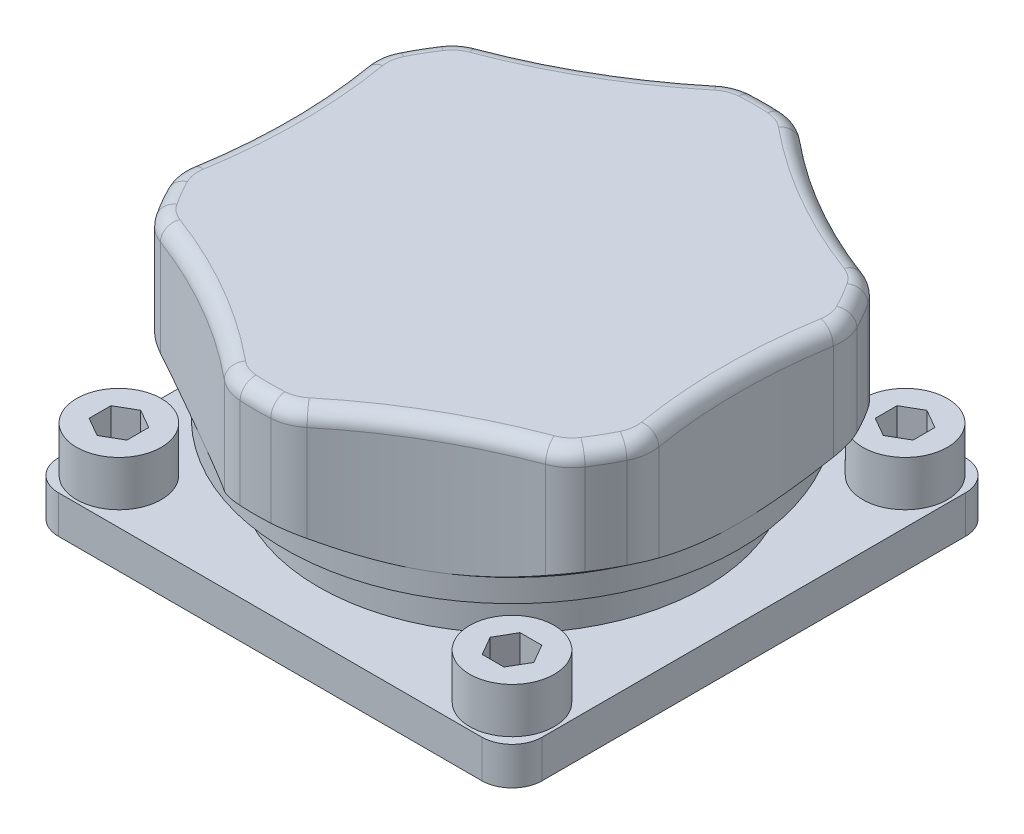
from build123d import *

# Parameters (mm, degrees)
EXTRUDE_1_DEPTH          = 2.5
SKETCH_2_R               = 12.8
EXTRUDE_2_DEPTH          = 10
EXTRUDE_START            = 3.25
SKETCH_3_R               = 17
EXTRUDE_3_DEPTH          = 10
SKETCH_5_R               = 35
CUT_EXTRUDE_2_DEPTH      = 10
SKETCH_7_R               = 2.8
EXTRUDE_4_DEPTH          = 3
CUT_EXTRUDE_4_DEPTH      = 2
PATTERN_CIRCULAR_1_COUNT = 4
FILLET_1_R               = 3
FILLET_2_R               = 1


with BuildPart() as part:
    # 草图1 → 凸台-拉伸1 (new body)
    with BuildSketch(Plane(origin=(0, 0, 0), x_dir=(1, 0, 0), z_dir=(0, 1, 0))):
        with BuildLine():
            Line((14, -16), (-14, -16))
            ThreePointArc((-14, -16), (-15.414213562, -15.414213562), (-16, -14))
            Line((-16, -14), (-16, 14))
            ThreePointArc((-16, 14), (-15.414213562, 15.414213562), (-14, 16))
            Line((-14, 16), (14, 16))
            ThreePointArc((14, 16), (15.414213562, 15.414213562), (16, 14))
            Line((16, 14), (16, -14))
            ThreePointArc((16, -14), (15.414213562, -15.414213562), (14, -16))
        make_face()
    extrude(amount=EXTRUDE_1_DEPTH)

    # 草图2 → 凸台-拉伸2 (add)
    with BuildSketch(Plane(origin=(0, 2.5, 0), x_dir=(1, 0, 0), z_dir=(0, 1, 0))):
        Circle(SKETCH_2_R)
    extrude(amount=EXTRUDE_2_DEPTH)

    # 草图3 → 凸台-拉伸3 (add)
    with BuildSketch(Plane(origin=(0, 2.5, 0), x_dir=(1, 0, 0), z_dir=(0, 1, 0)).offset(EXTRUDE_START)):
        Circle(SKETCH_3_R)
    extrude(amount=EXTRUDE_3_DEPTH)

    # 草图4 → 切除-旋转1 (revolve, cut)
    with BuildSketch(Plane.XY):
        Polygon((-17, 5.75), (-15, 5.75), (-15, 7.25), (-17, 8.75), align=None)
    revolve(axis=Axis((0, 0, 0), (0, 1, 0)), mode=Mode.SUBTRACT)

    # 草图5 → 切除-拉伸2 (cut)
    with BuildSketch(Plane(origin=(0, 15.75, 0), x_dir=(1, 0, 0), z_dir=(0, 1, 0))):
        with Locations((50, 0)):
            Circle(SKETCH_5_R)
        with Locations((25, -43.301270189)):
            Circle(SKETCH_5_R)
        with Locations((-25, -43.301270189)):
            Circle(SKETCH_5_R)
        with Locations((-50, 0)):
            Circle(SKETCH_5_R)
        with Locations((-25, 43.301270189)):
            Circle(SKETCH_5_R)
        with Locations((25, 43.301270189)):
            Circle(SKETCH_5_R)
    extrude(amount=-CUT_EXTRUDE_2_DEPTH, mode=Mode.SUBTRACT)

    # 草图7 → 凸台-拉伸4 (add)
    with BuildSketch(Plane(origin=(0, 2.5, 0), x_dir=(1, 0, 0), z_dir=(0, 1, 0))):
        with Locations((-13, -13)):
            Circle(SKETCH_7_R)
        with Locations((-13, 13)):
            Circle(SKETCH_7_R)
        with Locations((13, 13)):
            Circle(SKETCH_7_R)
        with Locations((13, -13)):
            Circle(SKETCH_7_R)
    extrude(amount=EXTRUDE_4_DEPTH)

    # 草图8 → 切除-拉伸4 (cut)
    with BuildSketch(Plane(origin=(0, 5.5, 0), x_dir=(1, 0, 0), z_dir=(0, 1, 0))):
        Polygon((13, 14.443375673), (11.75, 13.721687836), (11.75, 12.278312164), (13, 11.556624327), (14.25, 12.278312164), (14.25, 13.721687836), align=None)
    cut_extrude_4 = extrude(amount=-CUT_EXTRUDE_4_DEPTH, mode=Mode.SUBTRACT)

    # 阵列(圆周)1: 切除-拉伸4 ×4 about axis
    pattern_circular_1_axis = Axis((0, 0, 0), (0, 1, 0))
    for i in range(1, PATTERN_CIRCULAR_1_COUNT):
        add(cut_extrude_4.rotate(pattern_circular_1_axis, i * 360 / PATTERN_CIRCULAR_1_COUNT), mode=Mode.SUBTRACT)

    # 圆角1
    fillet_1_edges = [part.edges().sort_by_distance(p)[0] for p in [
        (-15.64, 12.25, 6.6626121),
        (-15.64, 12.2499997, -6.6626121),
        (-2.050008666, 12.25, 16.875943365),
        (-13.589991334, 12.25, 10.213331265),
        (13.589991334, 12.25, 10.213331265),
        (2.050008666, 12.25, 16.875943365),
        (15.64, 12.25, -6.6626121),
        (15.64, 12.25, 6.6626121),
        (-13.589991334, 12.25, -10.213331265),
        (-2.050008666, 12.25, -16.875943365),
        (2.050008666, 12.25, -16.875943365),
        (13.589991334, 12.25, -10.213331265),
    ]]
    fillet(fillet_1_edges, radius=FILLET_1_R)

    # 圆角2
    fillet_2_edges = [part.edges().sort_by_distance(p)[0] for p in [
        (-14.722431864, 15.75, -8.5),
        (7.5, 15.75, -12.990381057),
        (0, 15.75, -17),
        (-7.5, 15.75, -12.990381057),
        (-15, 15.75, 0),
        (-14.722431864, 15.75, 8.5),
        (-7.5, 15.75, 12.990381057),
        (0, 15.75, 17),
        (7.5, 15.75, 12.990381057),
        (14.722431864, 15.75, 8.5),
        (15, 15.75, 0),
        (14.722431864, 15.75, -8.5),
        (15.486684182, 15.75, -6.710803192),
        (13.555068135, 15.75, -10.056460326),
        (1.931616047, 15.75, -16.767263518),
        (-1.931616047, 15.75, -16.767263518),
        (-13.555068135, 15.75, -10.056460326),
        (15.486684182, 15.75, 6.710803192),
        (13.555068135, 15.75, 10.056460326),
        (1.931616047, 15.75, 16.767263518),
        (-1.931616047, 15.75, 16.767263518),
        (-13.555068135, 15.75, 10.056460326),
        (-15.486684182, 15.75, 6.710803192),
        (-15.486684182, 15.75, -6.710803192),
    ]]
    fillet(fillet_2_edges, radius=FILLET_2_R)


solid = part.part
